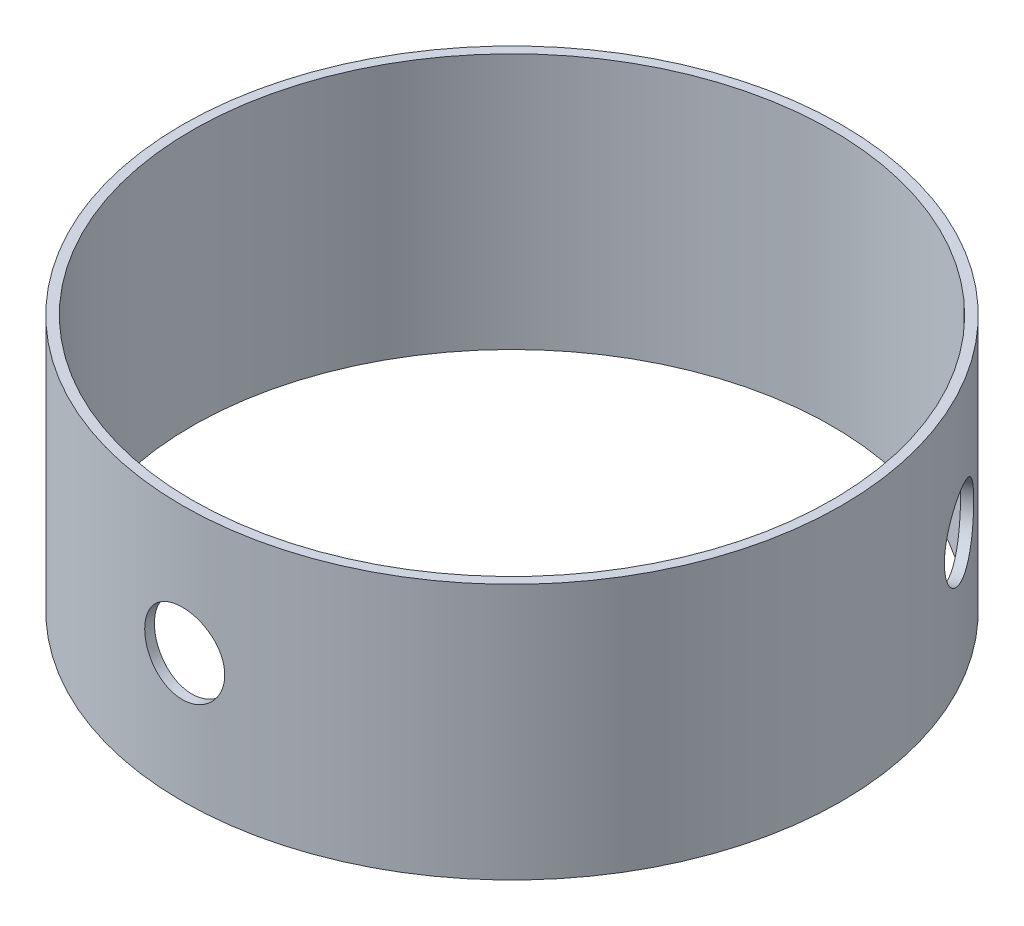
from build123d import *

# Parameters (mm, degrees)
SKETCH1_R                        = 65.405
SKETCH1_R_2                      = 63.5
BOSS_EXTRUDE1_DEPTH              = 25.4
F_5_8_0_625_DIAMETER_HOLE1_D     = 15.875
F_5_8_0_625_DIAMETER_HOLE1_DEPTH = 3.81
F_5_8_0_625_DIAMETER_HOLE2_D     = 15.875
F_5_8_0_625_DIAMETER_HOLE2_DEPTH = 3.81


with BuildPart() as part:
    # Sketch1 → Boss-Extrude1 (new body, symmetric)
    with BuildSketch(Plane(origin=(0, 0, 0), x_dir=(1, 0, 0), z_dir=(0, 1, 0))):
        Circle(SKETCH1_R)
        Circle(SKETCH1_R_2, mode=Mode.SUBTRACT)
    extrude(amount=BOSS_EXTRUDE1_DEPTH, both=True)

    # 5/8 (0.625) Diameter Hole1
    with Locations(Plane(origin=(56.642391535, 0, -32.7025), x_dir=(0, -1, 0), z_dir=(0.866025404, 0, -0.5))):
        with Locations((0, 0)):
            Hole(F_5_8_0_625_DIAMETER_HOLE1_D / 2, depth=F_5_8_0_625_DIAMETER_HOLE1_DEPTH)

    # 5/8 (0.625) Diameter Hole2
    with Locations(Plane.XY.offset(65.405)):
        with Locations((0, 0)):
            Hole(F_5_8_0_625_DIAMETER_HOLE2_D / 2, depth=F_5_8_0_625_DIAMETER_HOLE2_DEPTH)


solid = part.part
